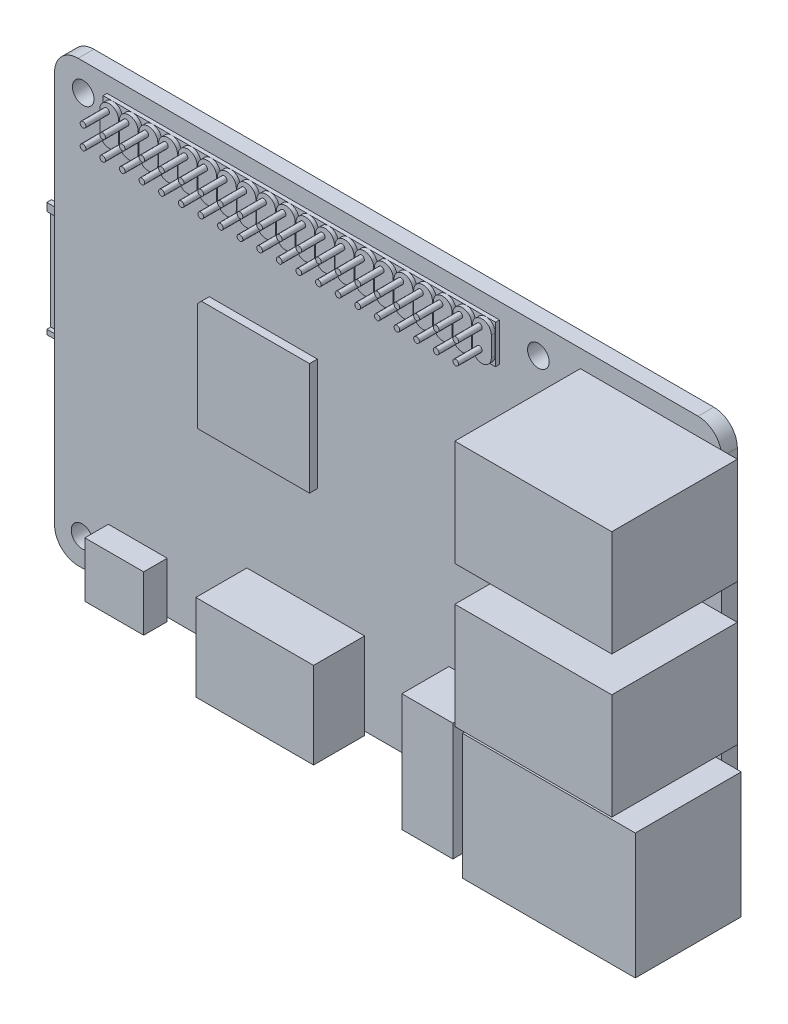
from build123d import *

# Parameters (mm, degrees)
BOSS_EXTRU_6_DEPTH      = 2
BOSS_EXTRU_8_DEPTH      = 1
ESQUISSE19_W            = 50.000582169
ESQUISSE19_H            = 4.923492373
BOSS_EXTRU_9_DEPTH      = 0.5
ESQUISSE20_R            = 0.361395421
BOSS_EXTRU_10_DEPTH     = 3
BOSS_EXTRU_11_DEPTH     = 1
BOSS_EXTRU_12_DEPTH     = 1
ESQUISSE23_R            = 1.375
ENL_V_MAT_EXTRU_1_DEPTH = 21
ESQUISSE24_W            = 17.6
ESQUISSE24_H            = 14.6
BOSS_EXTRU_13_DEPTH     = 0.6
ESQUISSE25_W            = 0.5
ESQUISSE25_H            = 13
ENL_V_MAT_EXTRU_2_DEPTH = 11
SKETCH1_W               = 7.5
SKETCH1_H               = 7
BOSS_EXTRUDE1_DEPTH     = 3
SKETCH2_W               = 22
SKETCH2_H               = 16
BOSS_EXTRUDE2_DEPTH     = 13.5
SKETCH3_W               = 15
SKETCH3_H               = 11
BOSS_EXTRUDE3_DEPTH     = 6.5
SKETCH4_W               = 6.5
SKETCH4_H               = 15
BOSS_EXTRUDE4_DEPTH     = 6
SKETCH5_R               = 1.75
CUT_EXTRUDE1_DEPTH      = 12
SKETCH6_W               = 20
SKETCH6_H               = 13.5
BOSS_EXTRUDE5_DEPTH     = 16
SKETCH7_W               = 20
SKETCH7_H               = 13.5
BOSS_EXTRUDE6_DEPTH     = 16


with BuildPart() as part:
    # Esquisse13 → Boss.-Extru.6 (new body)
    with BuildSketch(Plane.XY):
        with BuildLine():
            Line((32.305129896, 232.75292532), (111.305129896, 232.75292532))
            ThreePointArc((111.305129896, 232.75292532), (113.42645024, 231.874245664), (114.305129896, 229.75292532))
            Line((114.305129896, 229.75292532), (114.305129896, 179.75292532))
            ThreePointArc((114.305129896, 179.75292532), (113.42645024, 177.631604977), (111.305129896, 176.75292532))
            Line((111.305129896, 176.75292532), (32.305129896, 176.75292532))
            ThreePointArc((32.305129896, 176.75292532), (30.183809552, 177.631604977), (29.305129896, 179.75292532))
            Line((29.305129896, 179.75292532), (29.305129896, 229.75292532))
            ThreePointArc((29.305129896, 229.75292532), (30.183809552, 231.874245664), (32.305129896, 232.75292532))
        make_face()
    extrude(amount=BOSS_EXTRU_6_DEPTH)

    # Esquisse18 → Boss.-Extru.8 (add)
    with BuildSketch(Plane.XY.offset(2)):
        with BuildLine():
            Line((38.45390288, 229.525786003), (38.45390288, 226.996845752))
            ThreePointArc((38.45390288, 226.996845752), (37.256626819, 225.799569691), (36.059350758, 226.996845752))
            Line((36.059350758, 226.996845752), (36.059350758, 229.525786003))
            ThreePointArc((36.059350758, 229.525786003), (37.256626819, 230.723062064), (38.45390288, 229.525786003))
        make_face()
        with BuildLine():
            Line((40.95390288, 229.525786003), (40.95390288, 226.996845752))
            ThreePointArc((40.95390288, 226.996845752), (39.756626819, 225.799569691), (38.559350758, 226.996845752))
            Line((38.559350758, 226.996845752), (38.559350758, 229.525786003))
            ThreePointArc((38.559350758, 229.525786003), (39.756626819, 230.723062064), (40.95390288, 229.525786003))
        make_face()
        with BuildLine():
            Line((43.45390288, 229.525786003), (43.45390288, 226.996845752))
            ThreePointArc((43.45390288, 226.996845752), (42.256626819, 225.799569691), (41.059350758, 226.996845752))
            Line((41.059350758, 226.996845752), (41.059350758, 229.525786003))
            ThreePointArc((41.059350758, 229.525786003), (42.256626819, 230.723062064), (43.45390288, 229.525786003))
        make_face()
        with BuildLine():
            Line((45.95390288, 229.525786003), (45.95390288, 226.996845752))
            ThreePointArc((45.95390288, 226.996845752), (44.756626819, 225.799569691), (43.559350758, 226.996845752))
            Line((43.559350758, 226.996845752), (43.559350758, 229.525786003))
            ThreePointArc((43.559350758, 229.525786003), (44.756626819, 230.723062064), (45.95390288, 229.525786003))
        make_face()
        with BuildLine():
            Line((48.45390288, 229.525786003), (48.45390288, 226.996845752))
            ThreePointArc((48.45390288, 226.996845752), (47.256626819, 225.799569691), (46.059350758, 226.996845752))
            Line((46.059350758, 226.996845752), (46.059350758, 229.525786003))
            ThreePointArc((46.059350758, 229.525786003), (47.256626819, 230.723062064), (48.45390288, 229.525786003))
        make_face()
        with BuildLine():
            Line((50.95390288, 229.525786003), (50.95390288, 226.996845752))
            ThreePointArc((50.95390288, 226.996845752), (49.756626819, 225.799569691), (48.559350758, 226.996845752))
            Line((48.559350758, 226.996845752), (48.559350758, 229.525786003))
            ThreePointArc((48.559350758, 229.525786003), (49.756626819, 230.723062064), (50.95390288, 229.525786003))
        make_face()
        with BuildLine():
            Line((53.45390288, 229.525786003), (53.45390288, 226.996845752))
            ThreePointArc((53.45390288, 226.996845752), (52.256626819, 225.799569691), (51.059350758, 226.996845752))
            Line((51.059350758, 226.996845752), (51.059350758, 229.525786003))
            ThreePointArc((51.059350758, 229.525786003), (52.256626819, 230.723062064), (53.45390288, 229.525786003))
        make_face()
        with BuildLine():
            Line((55.95390288, 229.525786003), (55.95390288, 226.996845752))
            ThreePointArc((55.95390288, 226.996845752), (54.756626819, 225.799569691), (53.559350758, 226.996845752))
            Line((53.559350758, 226.996845752), (53.559350758, 229.525786003))
            ThreePointArc((53.559350758, 229.525786003), (54.756626819, 230.723062064), (55.95390288, 229.525786003))
        make_face()
        with BuildLine():
            Line((58.45390288, 229.525786003), (58.45390288, 226.996845752))
            ThreePointArc((58.45390288, 226.996845752), (57.256626819, 225.799569691), (56.059350758, 226.996845752))
            Line((56.059350758, 226.996845752), (56.059350758, 229.525786003))
            ThreePointArc((56.059350758, 229.525786003), (57.256626819, 230.723062064), (58.45390288, 229.525786003))
        make_face()
        with BuildLine():
            Line((60.95390288, 229.525786003), (60.95390288, 226.996845752))
            ThreePointArc((60.95390288, 226.996845752), (59.756626819, 225.799569691), (58.559350758, 226.996845752))
            Line((58.559350758, 226.996845752), (58.559350758, 229.525786003))
            ThreePointArc((58.559350758, 229.525786003), (59.756626819, 230.723062064), (60.95390288, 229.525786003))
        make_face()
        with BuildLine():
            Line((63.45390288, 229.525786003), (63.45390288, 226.996845752))
            ThreePointArc((63.45390288, 226.996845752), (62.256626819, 225.799569691), (61.059350758, 226.996845752))
            Line((61.059350758, 226.996845752), (61.059350758, 229.525786003))
            ThreePointArc((61.059350758, 229.525786003), (62.256626819, 230.723062064), (63.45390288, 229.525786003))
        make_face()
        with BuildLine():
            Line((65.95390288, 229.525786003), (65.95390288, 226.996845752))
            ThreePointArc((65.95390288, 226.996845752), (64.756626819, 225.799569691), (63.559350758, 226.996845752))
            Line((63.559350758, 226.996845752), (63.559350758, 229.525786003))
            ThreePointArc((63.559350758, 229.525786003), (64.756626819, 230.723062064), (65.95390288, 229.525786003))
        make_face()
        with BuildLine():
            Line((68.45390288, 229.525786003), (68.45390288, 226.996845752))
            ThreePointArc((68.45390288, 226.996845752), (67.256626819, 225.799569691), (66.059350758, 226.996845752))
            Line((66.059350758, 226.996845752), (66.059350758, 229.525786003))
            ThreePointArc((66.059350758, 229.525786003), (67.256626819, 230.723062064), (68.45390288, 229.525786003))
        make_face()
        with BuildLine():
            Line((70.95390288, 229.525786003), (70.95390288, 226.996845752))
            ThreePointArc((70.95390288, 226.996845752), (69.756626819, 225.799569691), (68.559350758, 226.996845752))
            Line((68.559350758, 226.996845752), (68.559350758, 229.525786003))
            ThreePointArc((68.559350758, 229.525786003), (69.756626819, 230.723062064), (70.95390288, 229.525786003))
        make_face()
        with BuildLine():
            Line((73.45390288, 229.525786003), (73.45390288, 226.996845752))
            ThreePointArc((73.45390288, 226.996845752), (72.256626819, 225.799569691), (71.059350758, 226.996845752))
            Line((71.059350758, 226.996845752), (71.059350758, 229.525786003))
            ThreePointArc((71.059350758, 229.525786003), (72.256626819, 230.723062064), (73.45390288, 229.525786003))
        make_face()
        with BuildLine():
            Line((75.95390288, 229.525786003), (75.95390288, 226.996845752))
            ThreePointArc((75.95390288, 226.996845752), (74.756626819, 225.799569691), (73.559350758, 226.996845752))
            Line((73.559350758, 226.996845752), (73.559350758, 229.525786003))
            ThreePointArc((73.559350758, 229.525786003), (74.756626819, 230.723062064), (75.95390288, 229.525786003))
        make_face()
        with BuildLine():
            Line((78.45390288, 229.525786003), (78.45390288, 226.996845752))
            ThreePointArc((78.45390288, 226.996845752), (77.256626819, 225.799569691), (76.059350758, 226.996845752))
            Line((76.059350758, 226.996845752), (76.059350758, 229.525786003))
            ThreePointArc((76.059350758, 229.525786003), (77.256626819, 230.723062064), (78.45390288, 229.525786003))
        make_face()
        with BuildLine():
            Line((80.95390288, 229.525786003), (80.95390288, 226.996845752))
            ThreePointArc((80.95390288, 226.996845752), (79.756626819, 225.799569691), (78.559350758, 226.996845752))
            Line((78.559350758, 226.996845752), (78.559350758, 229.525786003))
            ThreePointArc((78.559350758, 229.525786003), (79.756626819, 230.723062064), (80.95390288, 229.525786003))
        make_face()
        with BuildLine():
            Line((83.45390288, 229.525786003), (83.45390288, 226.996845752))
            ThreePointArc((83.45390288, 226.996845752), (82.256626819, 225.799569691), (81.059350758, 226.996845752))
            Line((81.059350758, 226.996845752), (81.059350758, 229.525786003))
            ThreePointArc((81.059350758, 229.525786003), (82.256626819, 230.723062064), (83.45390288, 229.525786003))
        make_face()
        with BuildLine():
            Line((85.95390288, 229.525786003), (85.95390288, 226.996845752))
            ThreePointArc((85.95390288, 226.996845752), (84.756626819, 225.799569691), (83.559350758, 226.996845752))
            Line((83.559350758, 226.996845752), (83.559350758, 229.525786003))
            ThreePointArc((83.559350758, 229.525786003), (84.756626819, 230.723062064), (85.95390288, 229.525786003))
        make_face()
    extrude(amount=BOSS_EXTRU_8_DEPTH)

    # Esquisse19 → Boss.-Extru.9 (add)
    with BuildSketch(Plane.XY.offset(2)):
        with Locations((60.994551794, 228.261315878)):
            Rectangle(ESQUISSE19_W, ESQUISSE19_H)
    extrude(amount=BOSS_EXTRU_9_DEPTH)

    # Esquisse20 → Boss.-Extru.10 (add)
    with BuildSketch(Plane.XY.offset(3)):
        with Locations((36.923630674, 229.735044797)):
            Circle(ESQUISSE20_R)
        with Locations((36.923630674, 227.230180834)):
            Circle(ESQUISSE20_R)
        with Locations((39.423630674, 229.735044797)):
            Circle(ESQUISSE20_R)
        with Locations((39.423630674, 227.230180834)):
            Circle(ESQUISSE20_R)
        with Locations((41.923630674, 229.735044797)):
            Circle(ESQUISSE20_R)
        with Locations((41.923630674, 227.230180834)):
            Circle(ESQUISSE20_R)
        with Locations((44.423630674, 229.735044797)):
            Circle(ESQUISSE20_R)
        with Locations((44.423630674, 227.230180834)):
            Circle(ESQUISSE20_R)
        with Locations((46.923630674, 229.735044797)):
            Circle(ESQUISSE20_R)
        with Locations((46.923630674, 227.230180834)):
            Circle(ESQUISSE20_R)
        with Locations((49.423630674, 229.735044797)):
            Circle(ESQUISSE20_R)
        with Locations((49.423630674, 227.230180834)):
            Circle(ESQUISSE20_R)
        with Locations((51.923630674, 229.735044797)):
            Circle(ESQUISSE20_R)
        with Locations((51.923630674, 227.230180834)):
            Circle(ESQUISSE20_R)
        with Locations((54.423630674, 229.735044797)):
            Circle(ESQUISSE20_R)
        with Locations((54.423630674, 227.230180834)):
            Circle(ESQUISSE20_R)
        with Locations((56.923630674, 229.735044797)):
            Circle(ESQUISSE20_R)
        with Locations((56.923630674, 227.230180834)):
            Circle(ESQUISSE20_R)
        with Locations((59.423630674, 229.735044797)):
            Circle(ESQUISSE20_R)
        with Locations((59.423630674, 227.230180834)):
            Circle(ESQUISSE20_R)
        with Locations((61.923630674, 229.735044797)):
            Circle(ESQUISSE20_R)
        with Locations((61.923630674, 227.230180834)):
            Circle(ESQUISSE20_R)
        with Locations((64.423630674, 229.735044797)):
            Circle(ESQUISSE20_R)
        with Locations((64.423630674, 227.230180834)):
            Circle(ESQUISSE20_R)
        with Locations((66.923630674, 229.735044797)):
            Circle(ESQUISSE20_R)
        with Locations((66.923630674, 227.230180834)):
            Circle(ESQUISSE20_R)
        with Locations((69.423630674, 229.735044797)):
            Circle(ESQUISSE20_R)
        with Locations((69.423630674, 227.230180834)):
            Circle(ESQUISSE20_R)
        with Locations((71.923630674, 229.735044797)):
            Circle(ESQUISSE20_R)
        with Locations((71.923630674, 227.230180834)):
            Circle(ESQUISSE20_R)
        with Locations((74.423630674, 229.735044797)):
            Circle(ESQUISSE20_R)
        with Locations((74.423630674, 227.230180834)):
            Circle(ESQUISSE20_R)
        with Locations((76.923630674, 229.735044797)):
            Circle(ESQUISSE20_R)
        with Locations((76.923630674, 227.230180834)):
            Circle(ESQUISSE20_R)
        with Locations((79.423630674, 229.735044797)):
            Circle(ESQUISSE20_R)
        with Locations((79.423630674, 227.230180834)):
            Circle(ESQUISSE20_R)
        with Locations((81.923630674, 229.735044797)):
            Circle(ESQUISSE20_R)
        with Locations((81.923630674, 227.230180834)):
            Circle(ESQUISSE20_R)
        with Locations((84.423630674, 229.735044797)):
            Circle(ESQUISSE20_R)
        with Locations((84.423630674, 227.230180834)):
            Circle(ESQUISSE20_R)
    extrude(amount=BOSS_EXTRU_10_DEPTH)

    # Esquisse21 → Boss.-Extru.11 (add)
    with BuildSketch(Plane.XY.offset(2)):
        Polygon((48.488516054, 214.268809703), (49.016471277, 214.796764927), (62.788516054, 214.796764927), (62.788516054, 200.496764927), (48.488516054, 200.496764927), align=None)
        Polygon((91.803833516, 213.783801688), (92.074770526, 213.57243471), (92.074770526, 205.593801688), (83.904770526, 205.593801688), (83.904770526, 213.783801688), align=None)
    extrude(amount=BOSS_EXTRU_11_DEPTH)

    # Esquisse22 → Boss.-Extru.12 (add)
    with BuildSketch(Plane(origin=(0, 0, 0), x_dir=(-1, 0, 0), z_dir=(0, 0, -1))):
        Polygon((-77.907458558, 215.11992983), (-77.553508103, 215.473880284), (-65.83262736, 215.473880284), (-65.83262736, 203.327175091), (-77.907458558, 203.327175091), align=None)
    extrude(amount=BOSS_EXTRU_12_DEPTH)

    # Esquisse23 → Enlèv. mat.-Extru.1 (cut)
    with BuildSketch(Plane.XY.offset(2)):
        with Locations((32.951343617, 229.25292532)):
            Circle(ESQUISSE23_R)
        with Locations((32.805129896, 180.25292532)):
            Circle(ESQUISSE23_R)
        with Locations((90.805129896, 180.25292532)):
            Circle(ESQUISSE23_R)
        with Locations((90.951343617, 229.25292532)):
            Circle(ESQUISSE23_R)
    extrude(amount=-ENL_V_MAT_EXTRU_1_DEPTH, mode=Mode.SUBTRACT)

    # Esquisse24 → Boss.-Extru.13 (add)
    with BuildSketch(Plane(origin=(0, 0, 0), x_dir=(-1, 0, 0), z_dir=(0, 0, -1))):
        with Locations((-35.105129896, 205.55292532)):
            Rectangle(ESQUISSE24_W, ESQUISSE24_H)
    extrude(amount=BOSS_EXTRU_13_DEPTH)

    # Esquisse25 → Enlèv. mat.-Extru.2 (cut)
    with BuildSketch(Plane.ZY.offset(-26.305129896)):
        with Locations((-0.25, 205.35292532)):
            Rectangle(ESQUISSE25_W, ESQUISSE25_H)
    extrude(amount=-ENL_V_MAT_EXTRU_2_DEPTH, mode=Mode.SUBTRACT)

    # Sketch1 → Boss-Extrude1 (add)
    with BuildSketch(Plane.XY.offset(2)):
        with Locations((39.905129896, 179.75292532)):
            Rectangle(SKETCH1_W, SKETCH1_H)
    extrude(amount=BOSS_EXTRUDE1_DEPTH)

    # Sketch2 → Boss-Extrude2 (add)
    with BuildSketch(Plane.XY.offset(2)):
        with Locations((105.805129896, 188.25292532)):
            Rectangle(SKETCH2_W, SKETCH2_H)
    extrude(amount=BOSS_EXTRUDE2_DEPTH)

    # Sketch3 → Boss-Extrude3 (add)
    with BuildSketch(Plane.XY.offset(2)):
        with Locations((61.305129896, 181.75292532)):
            Rectangle(SKETCH3_W, SKETCH3_H)
    extrude(amount=BOSS_EXTRUDE3_DEPTH)

    # Sketch4 → Boss-Extrude4 (add)
    with BuildSketch(Plane.XY.offset(2)):
        with Locations((82.805129896, 181.75292532)):
            Rectangle(SKETCH4_W, SKETCH4_H)
    extrude(amount=BOSS_EXTRUDE4_DEPTH)

    # Sketch5 → Cut-Extrude1 (cut)
    with BuildSketch(Plane.XZ.offset(-174.25292532)):
        with Locations((82.805129896, 5.103224555)):
            Circle(SKETCH5_R)
    extrude(amount=-CUT_EXTRUDE1_DEPTH, mode=Mode.SUBTRACT)

    # Sketch6 → Boss-Extrude5 (add)
    with BuildSketch(Plane.XY.offset(2)):
        with Locations((106.305129896, 205.75292532)):
            Rectangle(SKETCH6_W, SKETCH6_H)
    extrude(amount=BOSS_EXTRUDE5_DEPTH)

    # Sketch7 → Boss-Extrude6 (add)
    with BuildSketch(Plane.XY.offset(2)):
        with Locations((106.305129896, 223.75292532)):
            Rectangle(SKETCH7_W, SKETCH7_H)
    extrude(amount=BOSS_EXTRUDE6_DEPTH)


solid = part.part
